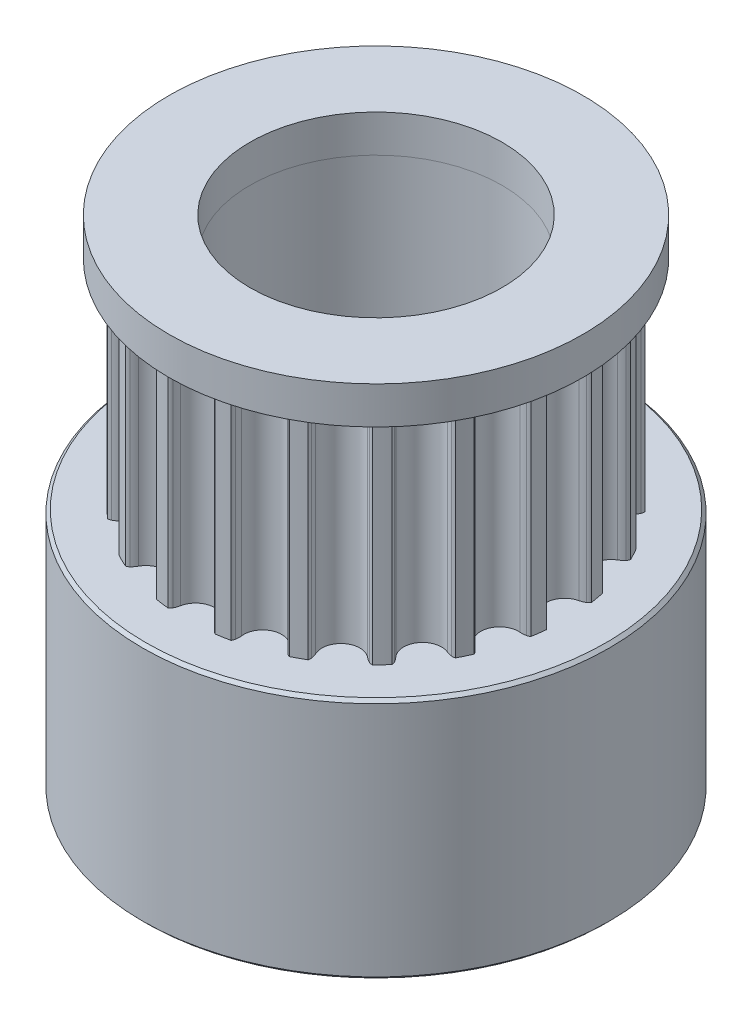
from build123d import *

# Parameters (mm, degrees)
P_IDAT_START            = 7.8
SKICA1_R                = 2.5
P_IDAT_VYSUNUT_M1_DEPTH = 7
SKICA2_R                = 3.5
SKICA2_R_2              = 2.5
P_IDAT_VYSUNUT_M2_DEPTH = 7.8
SKICA3_R                = 3.5
SKICA3_R_2              = 2.5
P_IDAT_VYSUNUT_M3_DEPTH = 1.2
SKICA5_R                = 7.5
SKICA5_R_2              = 3.5
P_IDAT_VYSUNUT_M4_DEPTH = 1.2
SKICA6_R                = 7.5
SKICA6_R_2              = 3.5
P_IDAT_VYSUNUT_M5_DEPTH = 7.8
ZKOSEN_1_SIZE           = 0.1
ZKOSEN_2_SIZE           = 0.1
ZKOSEN_3_SIZE           = 0.1
SKETCH8_OUTSIDE_W       = 22.314
SKETCH8_OUTSIDE_H       = 22.314
SKETCH8_OUTSIDE_R       = 6.65
CUT_EXTRUDE2_DEPTH      = 5
SKETCH19_R              = 1.5
CUT_EXTRUDE6_DEPTH      = 5
SKETCH20_R              = 1.5
CUT_EXTRUDE7_DEPTH      = 5
SKETCH7_R               = 4.05
CUT_EXTRUDE9_DEPTH      = 20


with BuildPart() as part:
    # Skica1 → Přidat vysunutím1 (new body)
    with BuildSketch(Plane(origin=(0, 0, 0), x_dir=(1, 0, 0), z_dir=(0, 1, 0)).offset(P_IDAT_START)):
        with BuildLine():
            ThreePointArc((-5.730143195, 1.098270155), (-5.09645097, 1.530497044), (-5.387174672, 2.240331989))
            ThreePointArc((-5.387174672, 2.240331989), (-5.468060657, 2.292707421), (-5.540463547, 2.356296335))
            ThreePointArc((-5.540463547, 2.356296335), (-5.573874331, 2.399596558), (-5.596043873, 2.44959357))
            ThreePointArc((-5.596043873, 2.44959357), (-5.50369925, 2.650567912), (-5.404139771, 2.848067596))
            ThreePointArc((-5.404139771, 2.848067596), (-5.351227535, 2.86190541), (-5.296542742, 2.862779021))
            ThreePointArc((-5.296542742, 2.862779021), (-5.201685094, 2.845815675), (-5.110305882, 2.815228615))
            ThreePointArc((-5.110305882, 2.815228615), (-4.374063308, 3.030479148), (-4.431206919, 3.795410862))
            ThreePointArc((-4.431206919, 3.795410862), (-4.491949163, 3.870218002), (-4.541158349, 3.953068377))
            ThreePointArc((-4.541158349, 3.953068377), (-4.559553388, 4.004573836), (-4.565187949, 4.058974585))
            ThreePointArc((-4.565187949, 4.058974585), (-4.415258506, 4.221576484), (-4.259541056, 4.378644275))
            ThreePointArc((-4.259541056, 4.378644275), (-4.204942409, 4.375454038), (-4.15266412, 4.359386362))
            ThreePointArc((-4.15266412, 4.359386362), (-4.067691098, 4.313940635), (-3.990236225, 4.256612884))
            ThreePointArc((-3.990236225, 4.256612884), (-3.223511854, 4.233816838), (-3.041481758, 4.978968476))
            ThreePointArc((-3.041481758, 4.978968476), (-3.076134388, 5.06888468), (-3.097332931, 5.162886543))
            ThreePointArc((-3.097332931, 5.162886543), (-3.09891159, 5.217555525), (-3.08745962, 5.271034888))
            ThreePointArc((-3.08745962, 5.271034888), (-2.894621497, 5.379347737), (-2.697988784, 5.480608745))
            ThreePointArc((-2.697988784, 5.480608745), (-2.647048223, 5.460702739), (-2.6022938, 5.429266591))
            ThreePointArc((-2.6022938, 5.429266591), (-2.535523156, 5.359787029), (-2.479574443, 5.281330225))
            ThreePointArc((-2.479574443, 5.281330225), (-1.7574206, 5.022719037), (-1.354035171, 5.675149965))
            ThreePointArc((-1.354035171, 5.675149965), (-1.359206146, 5.771373608), (-1.350318985, 5.867325402))
            ThreePointArc((-1.350318985, 5.867325402), (-1.334926735, 5.919806527), (-1.307509232, 5.967129569))
            ThreePointArc((-1.307509232, 5.967129569), (-1.090638767, 6.010550954), (-0.872338572, 6.046093045))
            ThreePointArc((-0.872338572, 6.046093045), (-0.830042514, 6.01141981), (-0.797192832, 5.967692379))
            ThreePointArc((-0.797192832, 5.967692379), (-0.755160541, 5.880980125), (-0.726194639, 5.789074167))
            ThreePointArc((-0.726194639, 5.789074167), (-0.119300773, 5.319962501), (0.465953812, 5.815808234))
            ThreePointArc((0.465953812, 5.815808234), (0.490770664, 5.908920276), (0.528873591, 5.997429571))
            ThreePointArc((0.528873591, 5.997429571), (0.55973005, 6.04258562), (0.600429269, 6.079120034))
            ThreePointArc((0.600429269, 6.079120034), (0.820103284, 6.053399565), (1.038702217, 6.019743632))
            ThreePointArc((1.038702217, 6.019743632), (1.06821354, 5.973697225), (1.085942924, 5.921958857))
            ThreePointArc((1.085942924, 5.921958857), (1.099122448, 5.826501911), (1.098270155, 5.730143195))
            ThreePointArc((1.098270155, 5.730143195), (1.530497044, 5.09645097), (2.240331989, 5.387174672))
            ThreePointArc((2.240331989, 5.387174672), (2.292707421, 5.468060657), (2.356296335, 5.540463547))
            ThreePointArc((2.356296335, 5.540463547), (2.399596558, 5.573874331), (2.44959357, 5.596043873))
            ThreePointArc((2.44959357, 5.596043873), (2.650567912, 5.50369925), (2.848067596, 5.404139771))
            ThreePointArc((2.848067596, 5.404139771), (2.86190541, 5.351227535), (2.862779021, 5.296542742))
            ThreePointArc((2.862779021, 5.296542742), (2.845815675, 5.201685094), (2.815228615, 5.110305882))
            ThreePointArc((2.815228615, 5.110305882), (3.030479148, 4.374063308), (3.795410862, 4.431206919))
            ThreePointArc((3.795410862, 4.431206919), (3.870218002, 4.491949163), (3.953068377, 4.541158349))
            ThreePointArc((3.953068377, 4.541158349), (4.004573836, 4.559553388), (4.058974585, 4.565187949))
            ThreePointArc((4.058974585, 4.565187949), (4.221576484, 4.415258506), (4.378644275, 4.259541056))
            ThreePointArc((4.378644275, 4.259541056), (4.375454038, 4.204942409), (4.359386362, 4.15266412))
            ThreePointArc((4.359386362, 4.15266412), (4.313940635, 4.067691098), (4.256612884, 3.990236225))
            ThreePointArc((4.256612884, 3.990236225), (4.233816838, 3.223511854), (4.978968476, 3.041481758))
            ThreePointArc((4.978968476, 3.041481758), (5.06888468, 3.076134388), (5.162886543, 3.097332931))
            ThreePointArc((5.162886543, 3.097332931), (5.217555525, 3.09891159), (5.271034888, 3.08745962))
            ThreePointArc((5.271034888, 3.08745962), (5.379347737, 2.894621497), (5.480608745, 2.697988784))
            ThreePointArc((5.480608745, 2.697988784), (5.460702739, 2.647048223), (5.429266591, 2.6022938))
            ThreePointArc((5.429266591, 2.6022938), (5.359787029, 2.535523156), (5.281330225, 2.479574443))
            ThreePointArc((5.281330225, 2.479574443), (5.022719037, 1.7574206), (5.675149965, 1.354035171))
            ThreePointArc((5.675149965, 1.354035171), (5.771373608, 1.359206146), (5.867325402, 1.350318985))
            ThreePointArc((5.867325402, 1.350318985), (5.919806527, 1.334926735), (5.967129569, 1.307509232))
            ThreePointArc((5.967129569, 1.307509232), (6.010550954, 1.090638767), (6.046093045, 0.872338572))
            ThreePointArc((6.046093045, 0.872338572), (6.01141981, 0.830042514), (5.967692379, 0.797192832))
            ThreePointArc((5.967692379, 0.797192832), (5.880980125, 0.755160541), (5.789074167, 0.726194639))
            ThreePointArc((5.789074167, 0.726194639), (5.319962501, 0.119300773), (5.815808234, -0.465953812))
            ThreePointArc((5.815808234, -0.465953812), (5.908920276, -0.490770664), (5.997429571, -0.528873591))
            ThreePointArc((5.997429571, -0.528873591), (6.04258562, -0.55973005), (6.079120034, -0.600429269))
            ThreePointArc((6.079120034, -0.600429269), (6.053399565, -0.820103284), (6.019743632, -1.038702217))
            ThreePointArc((6.019743632, -1.038702217), (5.973697225, -1.06821354), (5.921958857, -1.085942924))
            ThreePointArc((5.921958857, -1.085942924), (5.826501911, -1.099122448), (5.730143195, -1.098270155))
            ThreePointArc((5.730143195, -1.098270155), (5.09645097, -1.530497044), (5.387174672, -2.240331989))
            ThreePointArc((5.387174672, -2.240331989), (5.468060657, -2.292707421), (5.540463547, -2.356296335))
            ThreePointArc((5.540463547, -2.356296335), (5.573874331, -2.399596558), (5.596043873, -2.44959357))
            ThreePointArc((5.596043873, -2.44959357), (5.50369925, -2.650567911), (5.404139771, -2.848067596))
            ThreePointArc((5.404139771, -2.848067596), (5.351227535, -2.86190541), (5.296542742, -2.862779021))
            ThreePointArc((5.296542742, -2.862779021), (5.201685094, -2.845815675), (5.110305882, -2.815228615))
            ThreePointArc((5.110305882, -2.815228615), (4.374063308, -3.030479148), (4.431206919, -3.795410862))
            ThreePointArc((4.431206919, -3.795410862), (4.491949163, -3.870218002), (4.541158349, -3.953068377))
            ThreePointArc((4.541158349, -3.953068377), (4.559553388, -4.004573836), (4.565187949, -4.058974585))
            ThreePointArc((4.565187949, -4.058974585), (4.415258506, -4.221576484), (4.259541056, -4.378644275))
            ThreePointArc((4.259541056, -4.378644275), (4.204942409, -4.375454038), (4.15266412, -4.359386362))
            ThreePointArc((4.15266412, -4.359386362), (4.067691098, -4.313940635), (3.990236225, -4.256612884))
            ThreePointArc((3.990236225, -4.256612884), (3.223511854, -4.233816838), (3.041481758, -4.978968476))
            ThreePointArc((3.041481758, -4.978968476), (3.076134388, -5.06888468), (3.097332931, -5.162886543))
            ThreePointArc((3.097332931, -5.162886543), (3.09891159, -5.217555525), (3.08745962, -5.271034888))
            ThreePointArc((3.08745962, -5.271034888), (2.894621497, -5.379347737), (2.697988784, -5.480608745))
            ThreePointArc((2.697988784, -5.480608745), (2.647048223, -5.460702739), (2.6022938, -5.429266591))
            ThreePointArc((2.6022938, -5.429266591), (2.535523156, -5.359787029), (2.479574443, -5.281330225))
            ThreePointArc((2.479574443, -5.281330225), (1.7574206, -5.022719037), (1.354035171, -5.675149965))
            ThreePointArc((1.354035171, -5.675149965), (1.359206146, -5.771373608), (1.350318985, -5.867325402))
            ThreePointArc((1.350318985, -5.867325402), (1.334926735, -5.919806527), (1.307509232, -5.967129569))
            ThreePointArc((1.307509232, -5.967129569), (1.090638767, -6.010550954), (0.872338572, -6.046093045))
            ThreePointArc((0.872338572, -6.046093045), (0.830042514, -6.01141981), (0.797192832, -5.967692379))
            ThreePointArc((0.797192832, -5.967692379), (0.755160541, -5.880980125), (0.726194639, -5.789074167))
            ThreePointArc((0.726194639, -5.789074167), (0.119300773, -5.319962501), (-0.465953812, -5.815808234))
            ThreePointArc((-0.465953812, -5.815808234), (-0.490770664, -5.908920276), (-0.528873591, -5.997429571))
            ThreePointArc((-0.528873591, -5.997429571), (-0.55973005, -6.04258562), (-0.600429269, -6.079120034))
            ThreePointArc((-0.600429269, -6.079120034), (-0.820103284, -6.053399565), (-1.038702217, -6.019743632))
            ThreePointArc((-1.038702217, -6.019743632), (-1.06821354, -5.973697225), (-1.085942924, -5.921958857))
            ThreePointArc((-1.085942924, -5.921958857), (-1.099122448, -5.826501911), (-1.098270155, -5.730143195))
            ThreePointArc((-1.098270155, -5.730143195), (-1.530497044, -5.09645097), (-2.240331989, -5.387174672))
            ThreePointArc((-2.240331989, -5.387174672), (-2.292707421, -5.468060657), (-2.356296335, -5.540463547))
            ThreePointArc((-2.356296335, -5.540463547), (-2.399596558, -5.573874331), (-2.44959357, -5.596043873))
            ThreePointArc((-2.44959357, -5.596043873), (-2.650567912, -5.50369925), (-2.848067596, -5.404139771))
            ThreePointArc((-2.848067596, -5.404139771), (-2.86190541, -5.351227535), (-2.862779021, -5.296542742))
            ThreePointArc((-2.862779021, -5.296542742), (-2.845815675, -5.201685094), (-2.815228615, -5.110305882))
            ThreePointArc((-2.815228615, -5.110305882), (-3.030479148, -4.374063308), (-3.795410862, -4.431206919))
            ThreePointArc((-3.795410862, -4.431206919), (-3.870218002, -4.491949163), (-3.953068377, -4.541158349))
            ThreePointArc((-3.953068377, -4.541158349), (-4.004573836, -4.559553388), (-4.058974585, -4.565187949))
            ThreePointArc((-4.058974585, -4.565187949), (-4.221576484, -4.415258506), (-4.378644275, -4.259541056))
            ThreePointArc((-4.378644275, -4.259541056), (-4.375454038, -4.204942409), (-4.359386362, -4.15266412))
            ThreePointArc((-4.359386362, -4.15266412), (-4.313940635, -4.067691098), (-4.256612884, -3.990236225))
            ThreePointArc((-4.256612884, -3.990236225), (-4.233816838, -3.223511854), (-4.978968476, -3.041481758))
            ThreePointArc((-4.978968476, -3.041481758), (-5.06888468, -3.076134388), (-5.162886543, -3.097332931))
            ThreePointArc((-5.162886543, -3.097332931), (-5.217555525, -3.09891159), (-5.271034888, -3.08745962))
            ThreePointArc((-5.271034888, -3.08745962), (-5.379347737, -2.894621497), (-5.480608745, -2.697988784))
            ThreePointArc((-5.480608745, -2.697988784), (-5.460702739, -2.647048223), (-5.429266591, -2.6022938))
            ThreePointArc((-5.429266591, -2.6022938), (-5.359787029, -2.535523156), (-5.281330225, -2.479574443))
            ThreePointArc((-5.281330225, -2.479574443), (-5.022719037, -1.7574206), (-5.675149965, -1.354035171))
            ThreePointArc((-5.675149965, -1.354035171), (-5.771373608, -1.359206146), (-5.867325402, -1.350318985))
            ThreePointArc((-5.867325402, -1.350318985), (-5.919806527, -1.334926735), (-5.967129569, -1.307509232))
            ThreePointArc((-5.967129569, -1.307509232), (-6.010550954, -1.090638767), (-6.046093045, -0.872338572))
            ThreePointArc((-6.046093045, -0.872338572), (-6.01141981, -0.830042514), (-5.967692379, -0.797192832))
            ThreePointArc((-5.967692379, -0.797192832), (-5.880980125, -0.755160541), (-5.789074167, -0.726194639))
            ThreePointArc((-5.789074167, -0.726194639), (-5.319962501, -0.119300773), (-5.815808234, 0.465953812))
            ThreePointArc((-5.815808234, 0.465953812), (-5.908920276, 0.490770664), (-5.997429571, 0.528873591))
            ThreePointArc((-5.997429571, 0.528873591), (-6.04258562, 0.55973005), (-6.079120034, 0.600429269))
            ThreePointArc((-6.079120034, 0.600429269), (-6.053399565, 0.820103284), (-6.019743632, 1.038702217))
            ThreePointArc((-6.019743632, 1.038702217), (-5.973697225, 1.06821354), (-5.921958857, 1.085942924))
            ThreePointArc((-5.921958857, 1.085942924), (-5.826501911, 1.099122448), (-5.730143195, 1.098270155))
        make_face()
        Circle(SKICA1_R, mode=Mode.SUBTRACT)
    extrude(amount=P_IDAT_VYSUNUT_M1_DEPTH)

    # Skica2 → Přidat vysunutím2 (add)
    with BuildSketch(Plane.XZ.offset(-7.8)):
        Circle(SKICA2_R)
        Circle(SKICA2_R_2, mode=Mode.SUBTRACT)
    extrude(amount=P_IDAT_VYSUNUT_M2_DEPTH)

    # Skica3 → Přidat vysunutím3 (add)
    with BuildSketch(Plane(origin=(0, 14.8, 0), x_dir=(1, 0, 0), z_dir=(0, 1, 0))):
        Circle(SKICA3_R)
        Circle(SKICA3_R_2, mode=Mode.SUBTRACT)
    extrude(amount=P_IDAT_VYSUNUT_M3_DEPTH)

    # Zkosení2
    zkosen_2_edges = [part.edges().sort_by_distance(p)[0] for p in [
        (-2.5, 0, 0),
        (-2.5, 16, 0),
    ]]
    chamfer(zkosen_2_edges, length=ZKOSEN_2_SIZE)


with BuildPart() as body_2:
    # Skica5 → Přidat vysunutím4 (new body)
    with BuildSketch(Plane(origin=(0, 16, 0), x_dir=(1, 0, 0), z_dir=(0, 1, 0))):
        Circle(SKICA5_R)
        Circle(SKICA5_R_2, mode=Mode.SUBTRACT)
    extrude(amount=-P_IDAT_VYSUNUT_M4_DEPTH)

    # Zkosení1
    zkosen_1_edges = [body_2.edges().sort_by_distance(p)[0] for p in [
        (-7.5, 16, 0),
        (-7.5, 14.8, 0),
    ]]
    chamfer(zkosen_1_edges, length=ZKOSEN_1_SIZE)

    # Sketch8 outside → Cut-Extrude2 (cut)
    with BuildSketch(Plane(origin=(0, 16, 0), x_dir=(1, 0, 0), z_dir=(0, 1, 0))):
        Rectangle(SKETCH8_OUTSIDE_W, SKETCH8_OUTSIDE_H)
        Circle(SKETCH8_OUTSIDE_R, mode=Mode.SUBTRACT)
    extrude(amount=-CUT_EXTRUDE2_DEPTH, mode=Mode.SUBTRACT)


with BuildPart() as body_3:
    # Skica6 → Přidat vysunutím5 (new body)
    with BuildSketch(Plane.XZ):
        Circle(SKICA6_R)
        Circle(SKICA6_R_2, mode=Mode.SUBTRACT)
    extrude(amount=-P_IDAT_VYSUNUT_M5_DEPTH)

    # Zkosení3
    zkosen_3_edges = [body_3.edges().sort_by_distance(p)[0] for p in [
        (-7.5, 0, 0),
        (-7.5, 7.8, 0),
    ]]
    chamfer(zkosen_3_edges, length=ZKOSEN_3_SIZE)

    # Sketch19 → Cut-Extrude6 (cut)
    with BuildSketch(Plane(origin=(0, 0, -7.5), x_dir=(-1, 0, 0), z_dir=(0, 0, -1))):
        with Locations((0, 3.9)):
            Circle(SKETCH19_R)
    extrude(amount=-CUT_EXTRUDE6_DEPTH, mode=Mode.SUBTRACT)

    # Sketch20 → Cut-Extrude7 (cut)
    with BuildSketch(Plane.ZY.offset(7.5)):
        with Locations((0, 3.9)):
            Circle(SKETCH20_R)
    extrude(amount=-CUT_EXTRUDE7_DEPTH, mode=Mode.SUBTRACT)


with BuildPart() as cut_extrude9_tool:
    # Sketch7 → Cut-Extrude9 (new body)
    with BuildSketch(Plane.XZ):
        Circle(SKETCH7_R)
    extrude(amount=-CUT_EXTRUDE9_DEPTH)


with BuildPart() as part_1:
    add(part.part)

    # Cut-Extrude9: cut by cut_extrude9_tool
    add(cut_extrude9_tool.part, mode=Mode.SUBTRACT)


with BuildPart() as body_2_1:
    add(body_2.part)

    # Cut-Extrude9: cut by cut_extrude9_tool
    add(cut_extrude9_tool.part, mode=Mode.SUBTRACT)


with BuildPart() as body_3_1:
    add(body_3.part)

    # Cut-Extrude9: cut by cut_extrude9_tool
    add(cut_extrude9_tool.part, mode=Mode.SUBTRACT)


solid = Compound([part_1.part, body_2_1.part, body_3_1.part])
